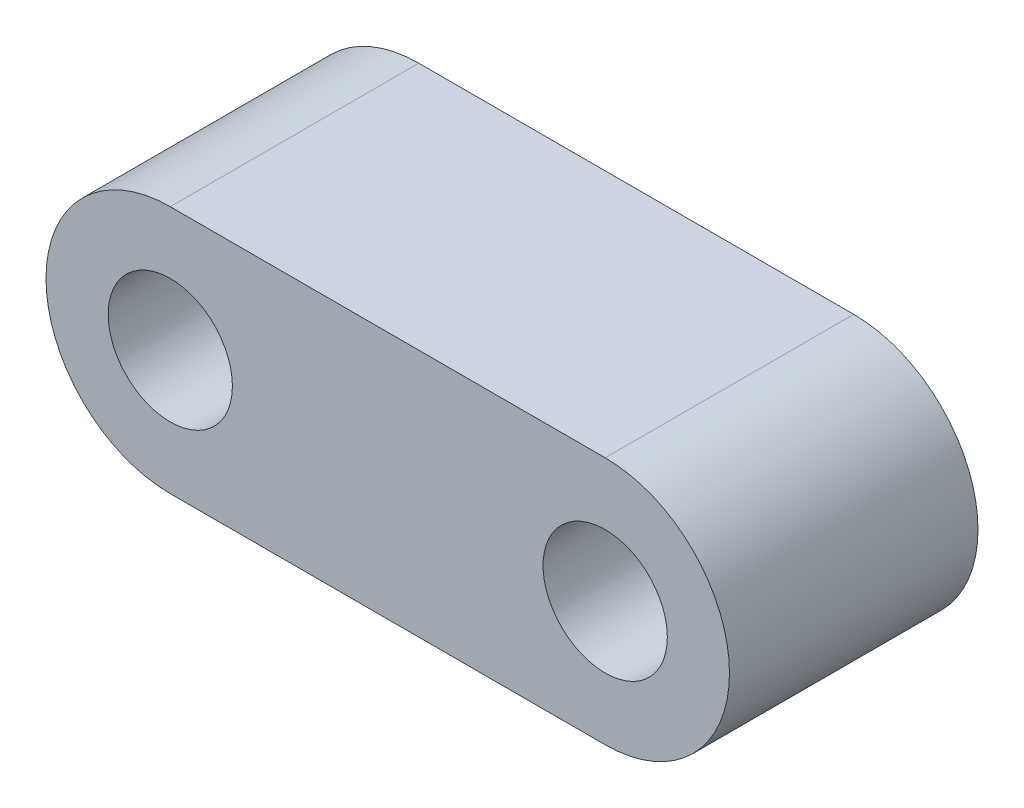
from build123d import *

# Parameters (mm, degrees)
CROQUIS1_R              = 10
SALIENTE_EXTRUIR1_DEPTH = 20


with BuildPart() as part:
    # Croquis1 → Saliente-Extruir1 (new body, symmetric)
    with BuildSketch(Plane.XY):
        with BuildLine():
            Line((0, -20), (70, -20))
            ThreePointArc((70, -20), (90, 0), (70, 20))
            Line((70, 20), (0, 20))
            ThreePointArc((0, 20), (-20, 0), (0, -20))
        make_face()
        with Locations((70, 0)):
            Circle(CROQUIS1_R, mode=Mode.SUBTRACT)
        Circle(CROQUIS1_R, mode=Mode.SUBTRACT)
    extrude(amount=SALIENTE_EXTRUIR1_DEPTH, both=True)


solid = part.part
